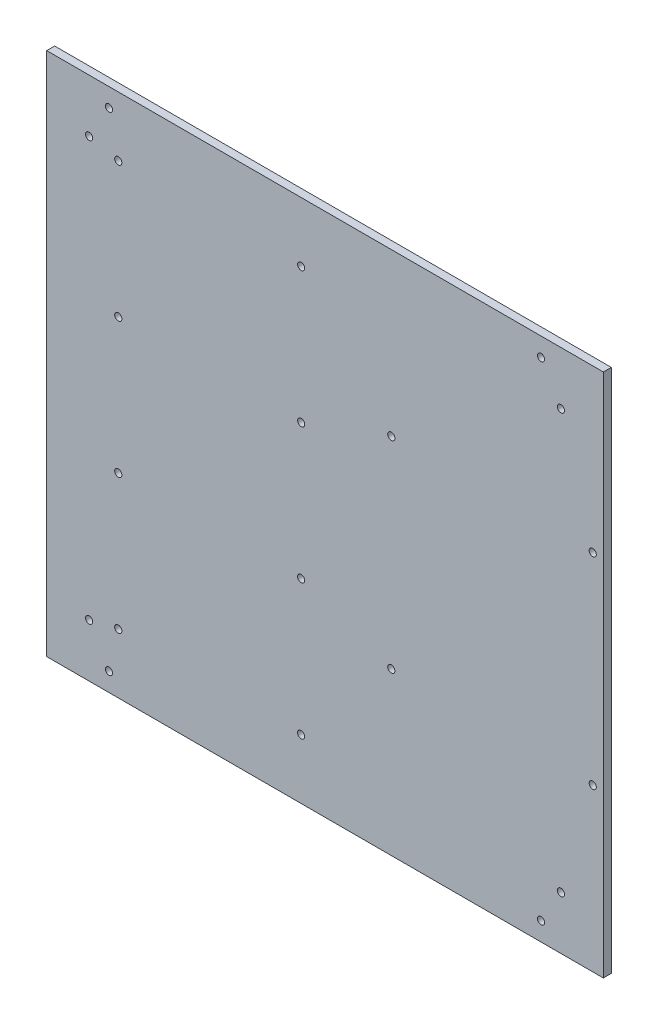
from build123d import *

# Parameters (mm, degrees)
ESQUISSE1_W            = 210
ESQUISSE1_H            = 198
BOSS_EXTRU_1_DEPTH     = 3
D_GAGEMENT_M2_51_D     = 2.7
D_GAGEMENT_M2_51_DEPTH = 3


with BuildPart() as part:
    # Esquisse1 → Boss.-Extru.1 (new body)
    with BuildSketch(Plane.XY):
        Rectangle(ESQUISSE1_W, ESQUISSE1_H)
    extrude(amount=BOSS_EXTRU_1_DEPTH)

    # Dégagement M2.51
    with Locations(Plane.XY.offset(3)):
        with Locations((-81.5, -92), (-89, -79), (-78, -76.5), (-78, -25.5), (-9, -76.5), (-9, -25.5), (-9, 25.5), (-78, 25.5), (-78, 76.5), (-89, 79), (-81.5, 92), (25, 38), (25, -38), (101, -38), (101, 38), (89, 79), (81.5, 92), (81.5, -92), (89, -79), (-9, 76.5)):
            Hole(D_GAGEMENT_M2_51_D / 2, depth=D_GAGEMENT_M2_51_DEPTH)


solid = part.part
